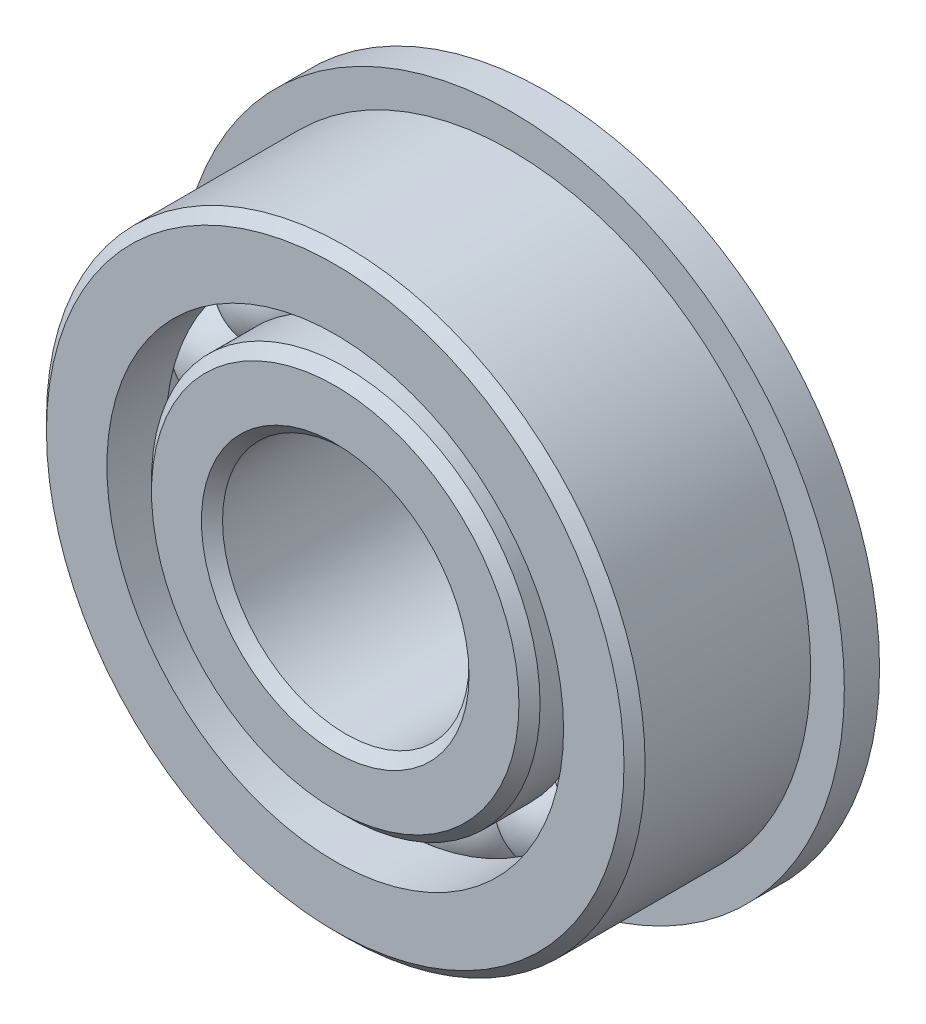
from build123d import *

# Parameters (mm, degrees)
CIRPATTERN1_COUNT = 15
SKETCH6_W         = 1.5875
SKETCH6_H         = 4.718817582


with BuildPart() as part:
    # Sketch1 → Revolve1 (revolve)
    with BuildSketch(Plane(origin=(0, 0, 0), x_dir=(0, 0, -1), z_dir=(1, 0, 0))):
        with BuildLine():
            Line((4.28625, 13.49375), (-4.28625, 13.49375))
            Line((-4.28625, 13.49375), (-4.7625, 13.0175))
            Line((-4.7625, 13.0175), (-4.7625, 10.292582418))
            Line((-4.7625, 10.292582418), (-2.116666667, 10.292582418))
            ThreePointArc((-2.116666667, 10.292582418), (0, 11.776546257), (2.116666667, 10.292582418))
            Line((2.116666667, 10.292582418), (4.7625, 10.292582418))
            Line((4.7625, 10.292582418), (4.7625, 13.0175))
            Line((4.7625, 13.0175), (4.28625, 13.49375))
        make_face()
    revolve(axis=Axis((0, 0, 4.7625), (0, 0, -1)))

    # Sketch6 → Revolve6 (revolve)
    with BuildSketch(Plane(origin=(0, 0, 0), x_dir=(0, 0, -1), z_dir=(1, 0, 0))):
        with Locations((3.96875, 12.651991209)):
            Rectangle(SKETCH6_W, SKETCH6_H)
    revolve(axis=Axis((0, 0, -4.7625), (0, 0, 1)))


with BuildPart() as body_2:
    # Sketch3 → Revolve3 (revolve)
    with BuildSketch(Plane(origin=(0, 0, 0), x_dir=(0, 0, -1), z_dir=(1, 0, 0))):
        with BuildLine():
            Line((-4.7625, 6.0325), (-4.7625, 8.281167582))
            Line((-4.7625, 8.281167582), (-4.28625, 8.757417582))
            Line((-4.28625, 8.757417582), (-2.116666667, 8.757417582))
            ThreePointArc((-2.116666667, 8.757417582), (0, 7.273453743), (2.116666667, 8.757417582))
            Line((2.116666667, 8.757417582), (5.87375, 8.757417582))
            Line((5.87375, 8.757417582), (6.35, 8.281167582))
            Line((6.35, 8.281167582), (6.35, 6.0325))
            Line((6.35, 6.0325), (5.87375, 5.55625))
            Line((5.87375, 5.55625), (-4.28625, 5.55625))
            Line((-4.28625, 5.55625), (-4.7625, 6.0325))
        make_face()
    revolve(axis=Axis((0, 0, 4.7625), (0, 0, -1)))


with BuildPart() as body_3:
    # Sketch4 → Revolve4 (revolve)
    with BuildSketch(Plane(origin=(0, 0, 0), x_dir=(0, 0, -1), z_dir=(1, 0, 0))):
        with BuildLine():
            Line((-2.251546257, 9.525), (2.251546257, 9.525))
            ThreePointArc((2.251546257, 9.525), (0, 11.776546257), (-2.251546257, 9.525))
        make_face()
    revolve(axis=Axis((0, 9.525, 2.251546257), (0, 0, -1)))


with BuildPart() as cirpattern1_1:
    # CirPattern1: pattern copy
    add(body_3.part.rotate(Axis((0, 0, -4.7625), (0, 0, 1)), 1 * 360 / CIRPATTERN1_COUNT))


with BuildPart() as cirpattern1_2:
    # CirPattern1: pattern copy
    add(body_3.part.rotate(Axis((0, 0, -4.7625), (0, 0, 1)), 2 * 360 / CIRPATTERN1_COUNT))


with BuildPart() as cirpattern1_3:
    # CirPattern1: pattern copy
    add(body_3.part.rotate(Axis((0, 0, -4.7625), (0, 0, 1)), 3 * 360 / CIRPATTERN1_COUNT))


with BuildPart() as cirpattern1_4:
    # CirPattern1: pattern copy
    add(body_3.part.rotate(Axis((0, 0, -4.7625), (0, 0, 1)), 4 * 360 / CIRPATTERN1_COUNT))


with BuildPart() as cirpattern1_5:
    # CirPattern1: pattern copy
    add(body_3.part.rotate(Axis((0, 0, -4.7625), (0, 0, 1)), 5 * 360 / CIRPATTERN1_COUNT))


with BuildPart() as cirpattern1_6:
    # CirPattern1: pattern copy
    add(body_3.part.rotate(Axis((0, 0, -4.7625), (0, 0, 1)), 6 * 360 / CIRPATTERN1_COUNT))


with BuildPart() as cirpattern1_7:
    # CirPattern1: pattern copy
    add(body_3.part.rotate(Axis((0, 0, -4.7625), (0, 0, 1)), 7 * 360 / CIRPATTERN1_COUNT))


with BuildPart() as cirpattern1_8:
    # CirPattern1: pattern copy
    add(body_3.part.rotate(Axis((0, 0, -4.7625), (0, 0, 1)), 8 * 360 / CIRPATTERN1_COUNT))


with BuildPart() as cirpattern1_9:
    # CirPattern1: pattern copy
    add(body_3.part.rotate(Axis((0, 0, -4.7625), (0, 0, 1)), 9 * 360 / CIRPATTERN1_COUNT))


with BuildPart() as cirpattern1_10:
    # CirPattern1: pattern copy
    add(body_3.part.rotate(Axis((0, 0, -4.7625), (0, 0, 1)), 10 * 360 / CIRPATTERN1_COUNT))


with BuildPart() as cirpattern1_11:
    # CirPattern1: pattern copy
    add(body_3.part.rotate(Axis((0, 0, -4.7625), (0, 0, 1)), 11 * 360 / CIRPATTERN1_COUNT))


with BuildPart() as cirpattern1_12:
    # CirPattern1: pattern copy
    add(body_3.part.rotate(Axis((0, 0, -4.7625), (0, 0, 1)), 12 * 360 / CIRPATTERN1_COUNT))


with BuildPart() as cirpattern1_13:
    # CirPattern1: pattern copy
    add(body_3.part.rotate(Axis((0, 0, -4.7625), (0, 0, 1)), 13 * 360 / CIRPATTERN1_COUNT))


with BuildPart() as cirpattern1_14:
    # CirPattern1: pattern copy
    add(body_3.part.rotate(Axis((0, 0, -4.7625), (0, 0, 1)), 14 * 360 / CIRPATTERN1_COUNT))


solid = Compound([part.part, body_2.part, body_3.part, cirpattern1_1.part, cirpattern1_2.part, cirpattern1_3.part, cirpattern1_4.part, cirpattern1_5.part, cirpattern1_6.part, cirpattern1_7.part, cirpattern1_8.part, cirpattern1_9.part, cirpattern1_10.part, cirpattern1_11.part, cirpattern1_12.part, cirpattern1_13.part, cirpattern1_14.part])
